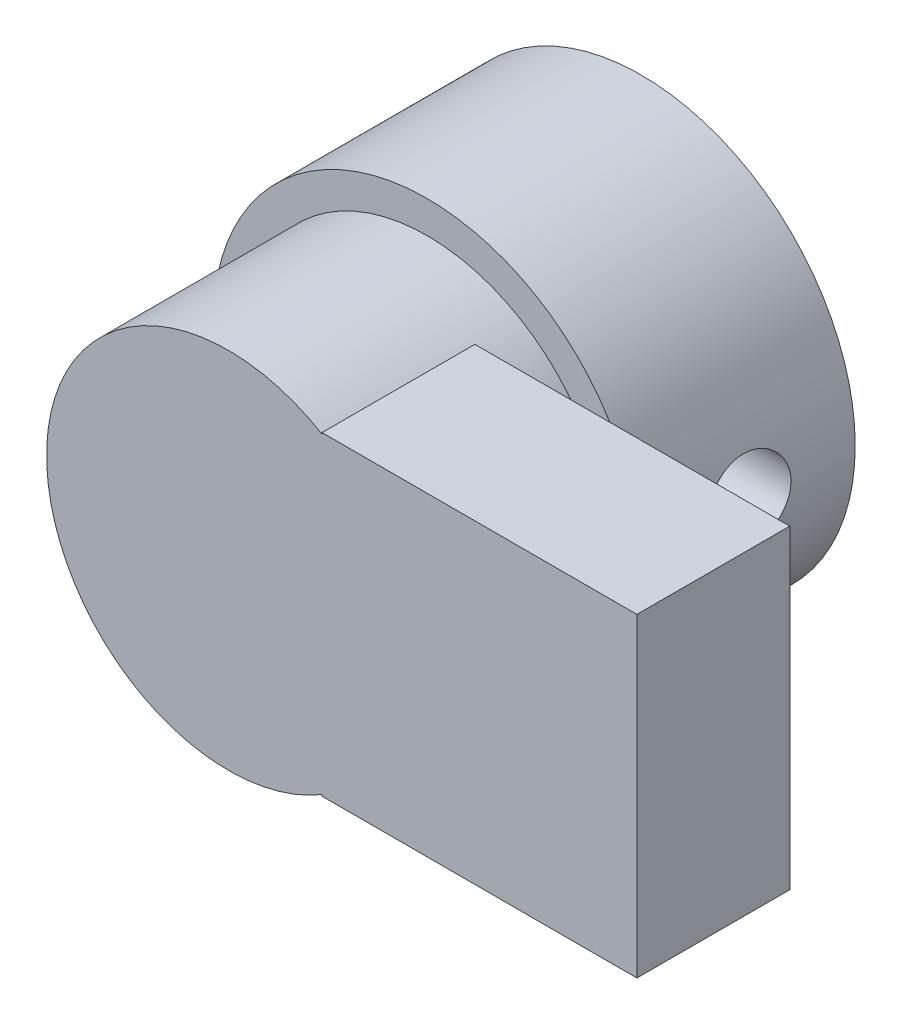
from build123d import *

# Parameters (mm, degrees)
SKETCH1_R           = 7
SKETCH1_R_2         = 4.075
BOSS_EXTRUDE1_DEPTH = 7
SKETCH2_R           = 5.95
BOSS_EXTRUDE2_DEPTH = 1.5
SKETCH3_R           = 5.95
SKETCH3_W           = 10.3
SKETCH3_H           = 10.3
BOSS_EXTRUDE3_DEPTH = 5
SKETCH4_R           = 1.4
CUT_EXTRUDE2_DEPTH  = 10


with BuildPart() as part:
    # Sketch1 → Boss-Extrude1 (new body)
    with BuildSketch(Plane.XY):
        with Locations((-3.892264878, 1.820575507)):
            Circle(SKETCH1_R)
        with Locations((-3.892264878, 1.820575507)):
            Circle(SKETCH1_R_2, mode=Mode.SUBTRACT)
    extrude(amount=BOSS_EXTRUDE1_DEPTH)

    # Sketch2 → Boss-Extrude2 (add)
    with BuildSketch(Plane.XY.offset(7)):
        with Locations((-3.892264878, 1.820575507)):
            Circle(SKETCH2_R)
    extrude(amount=BOSS_EXTRUDE2_DEPTH)

    # Sketch3 → Boss-Extrude3 (add)
    with BuildSketch(Plane.XY.offset(8.5)):
        with Locations((-3.892264878, 1.820575507)):
            Circle(SKETCH3_R)
        with Locations((4.316754573, 1.820575507)):
            Rectangle(SKETCH3_W, SKETCH3_H)
    extrude(amount=BOSS_EXTRUDE3_DEPTH)

    # Sketch4 → Cut-Extrude2 (cut)
    with BuildSketch(Plane(origin=(9.466754573, 0, 0), x_dir=(0, 0, -1), z_dir=(1, 0, 0))):
        with Locations((-3.5, 1.870575507)):
            Circle(SKETCH4_R)
    extrude(amount=-CUT_EXTRUDE2_DEPTH, mode=Mode.SUBTRACT)


solid = part.part
